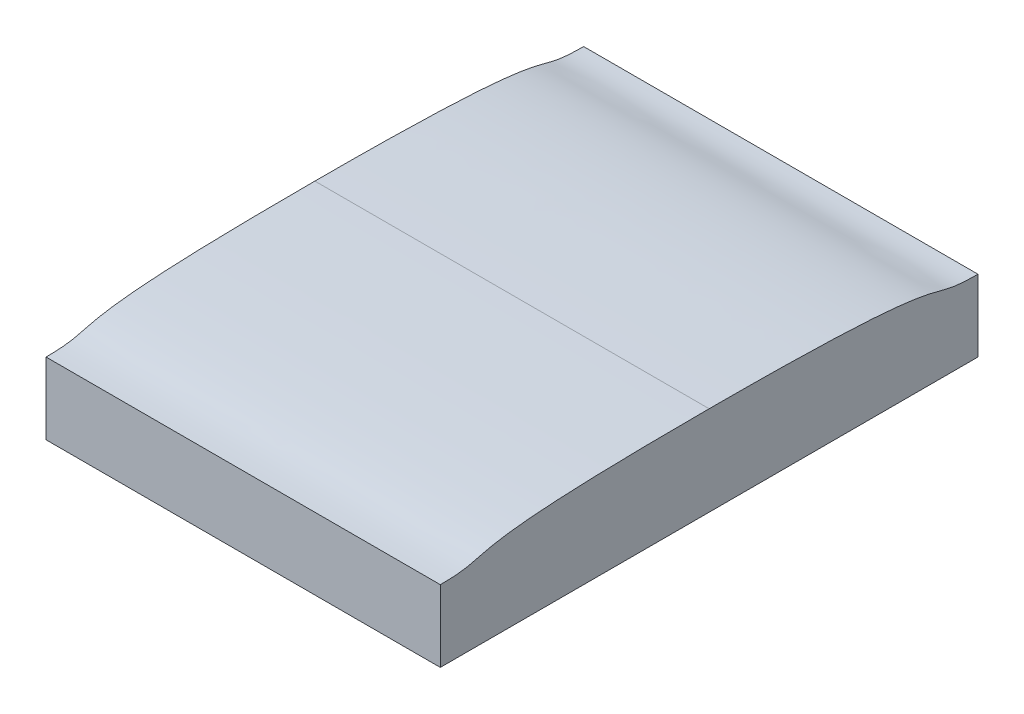
from build123d import *

# Parameters (mm, degrees)
BOSS_EXTRUDE1_DEPTH = 22


with BuildPart() as part:
    # Sketch1 → Boss-Extrude1 (new body)
    with BuildSketch(Plane(origin=(0, 0, 0), x_dir=(0, 0, -1), z_dir=(1, 0, 0))):
        with BuildLine():
            Line((15, -0.230657833), (15, 3.769342167))
            add(Edge.make_bspline(
                [(15, 3.769342167), (11.483472035, 3.769342167), (14.952461446, 4.769342167), (0, 4.769342167)],
                knots=[0, 0, 0, 0, 1, 1, 1, 1], degree=3))
            add(Edge.make_bspline(
                [(-15, 3.769342167), (-11.483472035, 3.769342167), (-14.952461446, 4.769342167), (0, 4.769342167)],
                knots=[0, 0, 0, 0, 1, 1, 1, 1], degree=3))
            Line((-15, 3.769342167), (-15, -0.230657833))
            add(Edge.make_bspline(
                [(-15, -0.230657833), (-10.389888521, -0.230657833), (-8.669092286, -0.230657833), (0, -0.230657833)],
                knots=[0, 0, 0, 0, 1, 1, 1, 1], degree=3))
            add(Edge.make_bspline(
                [(15, -0.230657833), (10.389888521, -0.230657833), (8.669092286, -0.230657833), (0, -0.230657833)],
                knots=[0, 0, 0, 0, 1, 1, 1, 1], degree=3))
        make_face()
    extrude(amount=BOSS_EXTRUDE1_DEPTH)


solid = part.part
